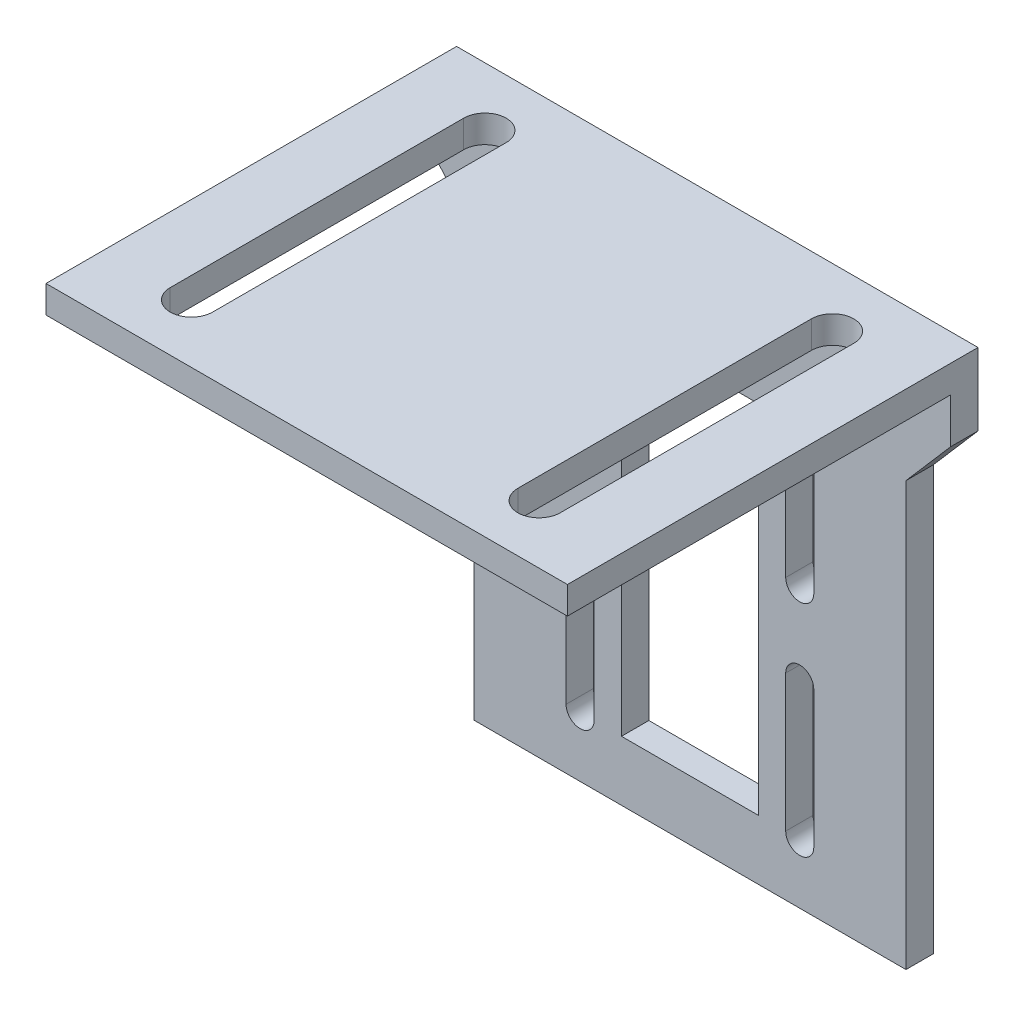
from build123d import *

# Parameters (mm, degrees)
BOSS_EXTRUDE1_DEPTH = 19.05
CUT_EXTRUDE1_DEPTH  = 19.05
SKETCH3_W           = 5
SKETCH3_H           = 26.05
CUT_EXTRUDE2_DEPTH  = 3


with BuildPart() as part:
    # Sketch1 → Boss-Extrude1 (new body, symmetric)
    with BuildSketch(Plane(origin=(0, 0, 0), x_dir=(0, 0, -1), z_dir=(1, 0, 0))):
        Polygon((0, 0), (-2, 0), (-2, 38), (-30, 38), (-30, 40), (0, 40), align=None)
    extrude(amount=BOSS_EXTRUDE1_DEPTH, both=True)

    # Sketch2 → Cut-Extrude1 (cut, symmetric)
    with BuildSketch(Plane(origin=(0, 40, 0), x_dir=(1, 0, 0), z_dir=(0, 1, 0))):
        with BuildLine():
            Line((11.15, -25.724165568), (11.15, -4.275834432))
            ThreePointArc((11.15, -4.275834432), (12.7, -2.725834432), (14.25, -4.275834432))
            Line((14.25, -4.275834432), (14.25, -25.724165568))
            ThreePointArc((14.25, -25.724165568), (12.7, -27.274165568), (11.15, -25.724165568))
        make_face()
        with BuildLine():
            Line((-11.15, -25.724165568), (-11.15, -4.275834432))
            ThreePointArc((-11.15, -4.275834432), (-12.7, -2.725834432), (-14.25, -4.275834432))
            Line((-14.25, -4.275834432), (-14.25, -25.724165568))
            ThreePointArc((-14.25, -25.724165568), (-12.7, -27.274165568), (-11.15, -25.724165568))
        make_face()
    extrude(amount=CUT_EXTRUDE1_DEPTH, both=True, mode=Mode.SUBTRACT)

    # Sketch3 → Cut-Extrude2 (cut, through all)
    with BuildSketch(Plane.XY.offset(2)):
        with Locations((2.5, 17.394531681)):
            Rectangle(SKETCH3_W, SKETCH3_H)
        with Locations((-2.5, 17.394531681)):
            Rectangle(SKETCH3_W, SKETCH3_H)
        with BuildLine():
            Line((-9.051280256, 30.419531681), (-9.051280256, 20.419531681))
            ThreePointArc((-9.051280256, 20.419531681), (-8.025, 19.393251425), (-6.998719744, 20.419531681))
            Line((-6.998719744, 20.419531681), (-6.998719744, 30.419531681))
            ThreePointArc((-6.998719744, 30.419531681), (-8.025, 31.445811938), (-9.051280256, 30.419531681))
        make_face()
        with BuildLine():
            Line((-9.051280256, 14.369531681), (-9.051280256, 4.369531681))
            ThreePointArc((-9.051280256, 4.369531681), (-8.025, 3.343251425), (-6.998719744, 4.369531681))
            Line((-6.998719744, 4.369531681), (-6.998719744, 14.369531681))
            ThreePointArc((-6.998719744, 14.369531681), (-8.025, 15.395811938), (-9.051280256, 14.369531681))
        make_face()
        with BuildLine():
            ThreePointArc((9.051280256, 20.419531681), (8.025, 19.393251425), (6.998719744, 20.419531681))
            Line((6.998719744, 20.419531681), (6.998719744, 30.419531681))
            ThreePointArc((6.998719744, 30.419531681), (8.025, 31.445811938), (9.051280256, 30.419531681))
            Line((9.051280256, 30.419531681), (9.051280256, 20.419531681))
        make_face()
        with BuildLine():
            ThreePointArc((9.051280256, 4.369531681), (8.025, 3.343251425), (6.998719744, 4.369531681))
            Line((6.998719744, 4.369531681), (6.998719744, 14.369531681))
            ThreePointArc((6.998719744, 14.369531681), (8.025, 15.395811938), (9.051280256, 14.369531681))
            Line((9.051280256, 14.369531681), (9.051280256, 4.369531681))
        make_face()
        Polygon((-15.786412439, 30.942427664), (-19.05, 34.716026675), (-19.05, 0), (-15.786412439, 0), align=None)
        Polygon((15.786412439, 30.942427664), (15.786412439, 0), (19.05, 0), (19.05, 34.716026675), align=None)
    extrude(amount=-CUT_EXTRUDE2_DEPTH, mode=Mode.SUBTRACT)


solid = part.part
